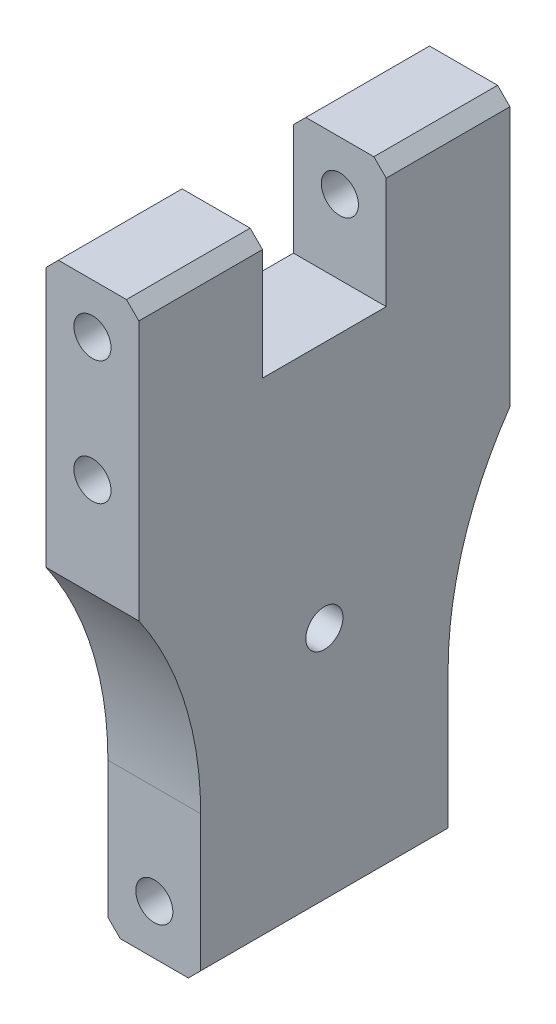
from build123d import *

# Parameters (mm, degrees)
BOSS_EXTRUDE1_DEPTH = 19.05
SKETCH2_R           = 3.81
CUT_EXTRUDE1_DEPTH  = 77.2
SKETCH3_R           = 3.81
CUT_EXTRUDE2_DEPTH  = 20.05
CHAMFER1_SIZE       = 2.54


with BuildPart() as part:
    # Sketch1 → Boss-Extrude1 (new body)
    with BuildSketch(Plane(origin=(0, 0, 0), x_dir=(0, 0, -1), z_dir=(1, 0, 0))):
        with BuildLine():
            Line((50.8, 0), (50.8, 30.48))
            ThreePointArc((50.8, 30.48), (54.048946048, 51.76907936), (63.5, 71.12))
            Line((63.5, 71.12), (63.5, 127))
            Line((63.5, 127), (38.1, 127))
            Line((38.1, 127), (38.1, 101.6))
            Line((38.1, 101.6), (12.7, 101.6))
            Line((12.7, 101.6), (12.7, 127))
            Line((12.7, 127), (-12.7, 127))
            Line((-12.7, 127), (-12.7, 71.12))
            ThreePointArc((-12.7, 71.12), (-3.248946048, 51.76907936), (0, 30.48))
            Line((0, 30.48), (0, 0))
            Line((0, 0), (50.8, 0))
        make_face()
    extrude(amount=BOSS_EXTRUDE1_DEPTH)

    # Sketch2 → Cut-Extrude1 (cut, through all)
    with BuildSketch(Plane.XY.offset(12.7)):
        with Locations((9.525, 116.84)):
            Circle(SKETCH2_R)
        with Locations((9.525, 91.44)):
            Circle(SKETCH2_R)
        with Locations((9.525, 10.16)):
            Circle(SKETCH2_R)
    extrude(amount=-CUT_EXTRUDE1_DEPTH, mode=Mode.SUBTRACT)

    # Sketch3 → Cut-Extrude2 (cut, through all)
    with BuildSketch(Plane(origin=(19.05, 0, 0), x_dir=(0, 0, -1), z_dir=(1, 0, 0))):
        with Locations((25.4, 50.8)):
            Circle(SKETCH3_R)
    extrude(amount=-CUT_EXTRUDE2_DEPTH, mode=Mode.SUBTRACT)

    # Chamfer1
    chamfer1_edges = [part.edges().sort_by_distance(p)[0] for p in [
        (0, 127, 0),
        (0, 127, -50.8),
        (0, 0, -25.4),
        (19.05, 127, -50.8),
        (19.05, 127, 0),
        (19.05, 0, -25.4),
    ]]
    chamfer(chamfer1_edges, length=CHAMFER1_SIZE)


solid = part.part
